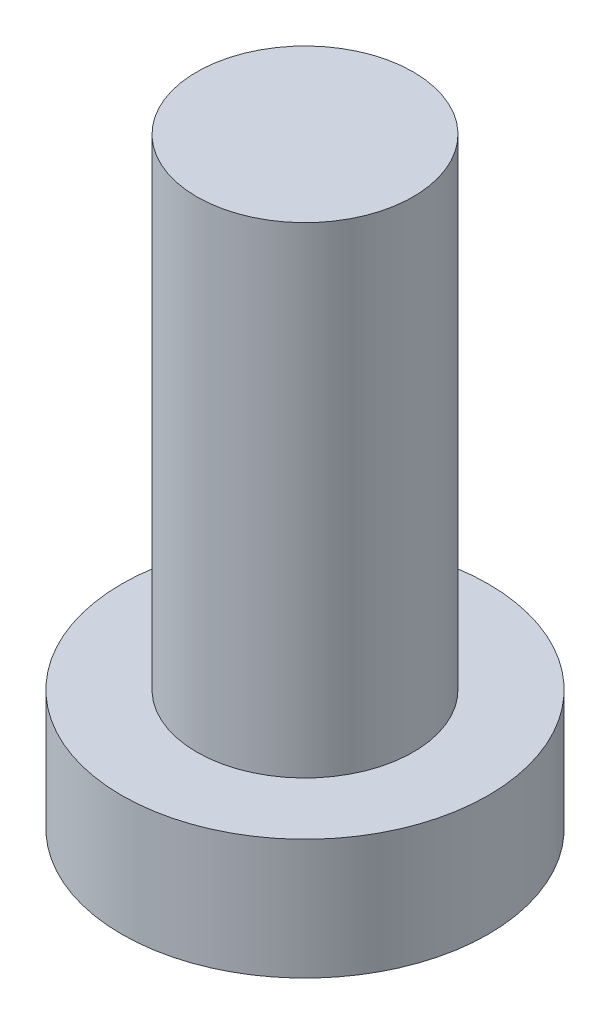
from build123d import *

# Parameters (mm, degrees)
SKETCH1_R           = 3.81
BOSS_EXTRUDE1_DEPTH = 2.5
SKETCH2_R           = 2.25
BOSS_EXTRUDE2_DEPTH = 10


with BuildPart() as part:
    # Sketch1 → Boss-Extrude1 (new body)
    with BuildSketch(Plane(origin=(0, 0, 0), x_dir=(1, 0, 0), z_dir=(0, 1, 0))):
        Circle(SKETCH1_R)
    extrude(amount=BOSS_EXTRUDE1_DEPTH)

    # Sketch2 → Boss-Extrude2 (add)
    with BuildSketch(Plane(origin=(0, 2.5, 0), x_dir=(1, 0, 0), z_dir=(0, 1, 0))):
        Circle(SKETCH2_R)
    extrude(amount=BOSS_EXTRUDE2_DEPTH)


solid = part.part
